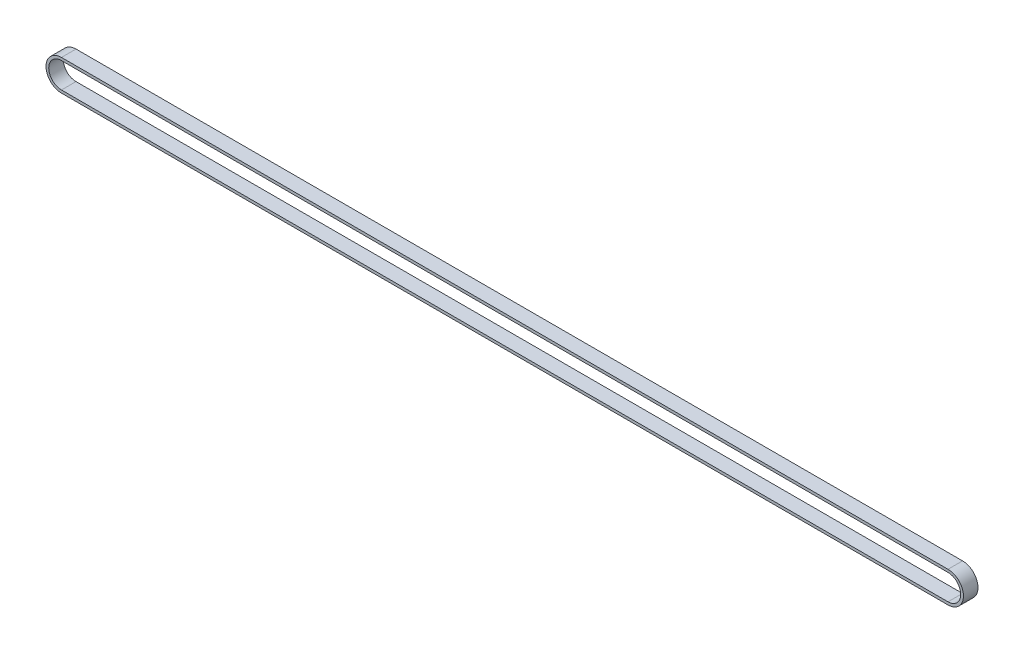
from build123d import *

# Parameters (mm, degrees)
ESTRUSIONE_ESTRUSIONE1_DEPTH = 6.4


with BuildPart() as part:
    # Schizzo1 → Estrusione-Estrusione1 (new body)
    with BuildSketch(Plane.XY):
        with BuildLine():
            Line((0, -6.8), (-390, -6.8))
            ThreePointArc((-390, -6.8), (-396.8, 0), (-390, 6.8))
            Line((-390, 6.8), (0, 6.8))
            ThreePointArc((0, 6.8), (6.8, 0), (0, -6.8))
        make_face()
        with BuildLine():
            Line((0, -5.6), (-390, -5.6))
            ThreePointArc((-390, -5.6), (-395.6, 0), (-390, 5.6))
            Line((-390, 5.6), (0, 5.6))
            ThreePointArc((0, 5.6), (5.6, 0), (0, -5.6))
        make_face(mode=Mode.SUBTRACT)
    extrude(amount=ESTRUSIONE_ESTRUSIONE1_DEPTH)


solid = part.part
